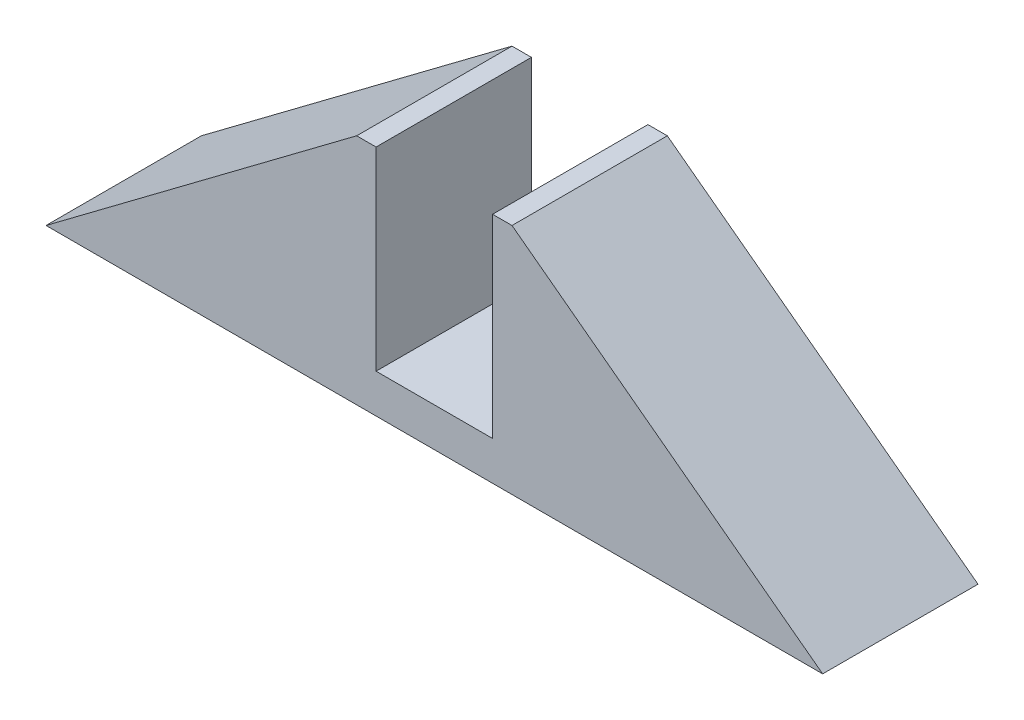
from build123d import *

# Parameters (mm, degrees)
SALIENTE_EXTRUIR1_DEPTH = 10
CROQUIS3_W              = 15
CROQUIS3_H              = 25
CORTAR_EXTRUIR1_DEPTH   = 20


with BuildPart() as part:
    # Croquis2 → Saliente-Extruir1 (new body, symmetric)
    with BuildSketch(Plane.XY):
        Polygon((-10, 15), (-50, -15), (-10, -15), (10, -15), (50, -15), (10, 15), align=None)
    extrude(amount=SALIENTE_EXTRUIR1_DEPTH, both=True)

    # Croquis3 → Cortar-Extruir1 (cut)
    with BuildSketch(Plane.XY.offset(10)):
        with Locations((0, 2.5)):
            Rectangle(CROQUIS3_W, CROQUIS3_H)
    extrude(amount=-CORTAR_EXTRUIR1_DEPTH, mode=Mode.SUBTRACT)


solid = part.part
